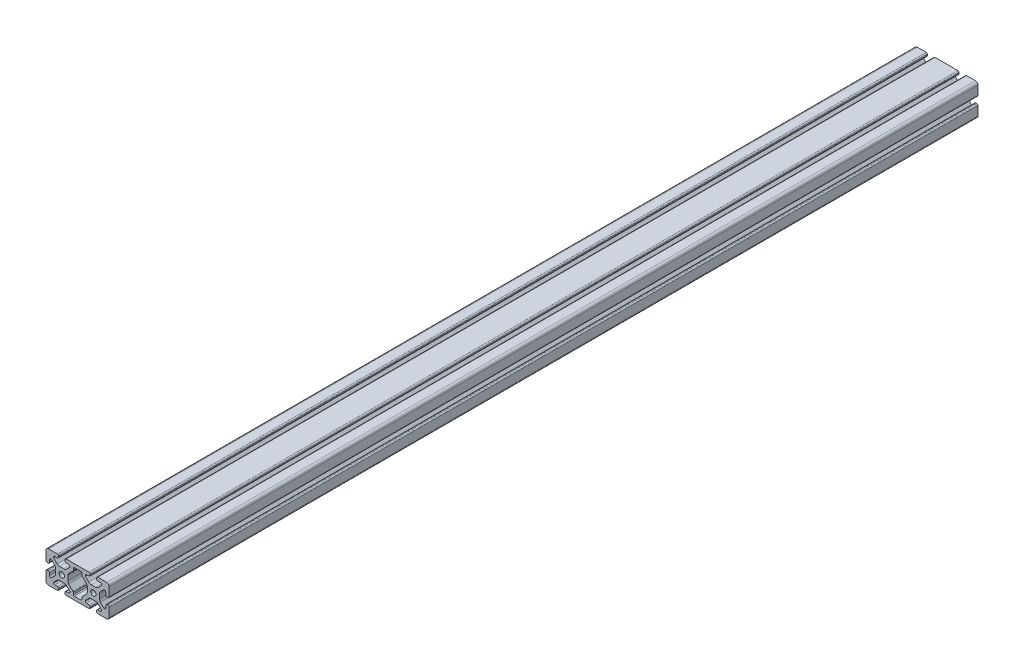
from build123d import *

# Parameters (mm, degrees)
SKETCH1_R           = 3.4
BOSS_EXTRUDE1_DEPTH = 1100


with BuildPart() as part:
    # Sketch1 → Boss-Extrude1 (new body)
    with BuildSketch(Plane.XY):
        with BuildLine():
            Line((-14.371895096, 20), (14.371895096, 20))
            ThreePointArc((14.371895096, 20), (15.50899084, 19.51254943), (15.94, 18.352883145))
            Line((15.94, 18.352883145), (15.94, 17.172883145))
            ThreePointArc((15.94, 17.172883145), (15.453758432, 16.112250378), (14.37, 15.68))
            Line((14.37, 15.68), (11.285, 15.68))
            ThreePointArc((11.285, 15.68), (10.174842354, 15.220157646), (9.715, 14.11))
            Line((9.715, 14.11), (9.715, 13.654503602))
            ThreePointArc((9.715, 13.654503602), (9.772851555, 13.363664194), (9.937598846, 13.117102448))
            Line((9.937598846, 13.117102448), (14.091872782, 8.962828513))
            ThreePointArc((14.091872782, 8.962828513), (15.647416634, 8.002049766), (17.450629992, 7.7))
            Line((17.450629992, 7.7), (22.549370008, 7.7))
            ThreePointArc((22.549370008, 7.7), (24.352583366, 8.002049766), (25.908127218, 8.962828513))
            Line((25.908127218, 8.962828513), (30.062401154, 13.117102448))
            ThreePointArc((30.062401154, 13.117102448), (30.227148445, 13.363664194), (30.285, 13.654503602))
            Line((30.285, 13.654503602), (30.285, 14.11))
            ThreePointArc((30.285, 14.11), (29.825157646, 15.220157646), (28.715, 15.68))
            Line((28.715, 15.68), (25.63, 15.68))
            ThreePointArc((25.63, 15.68), (24.519842354, 16.139842354), (24.06, 17.25))
            Line((24.06, 17.25), (24.06, 18.431164164))
            ThreePointArc((24.06, 18.431164164), (24.498672143, 19.519739968), (25.569550674, 20))
            Line((25.569550674, 20), (33, 20))
            Line((33, 20), (36.83, 20))
            ThreePointArc((36.83, 20), (39.067780363, 19.075288119), (40, 16.840624931))
            Line((40, 16.840624931), (40, 13.010624931))
            Line((40, 13.010624931), (40, 5.582508737))
            ThreePointArc((40, 5.582508737), (39.486387554, 4.464397964), (38.324306777, 4.06))
            Line((38.324306777, 4.06), (37.144306789, 4.06))
            ThreePointArc((37.144306789, 4.06), (36.103082753, 4.554299861), (35.68, 5.626438298))
            Line((35.68, 5.626438298), (35.68, 8.711438298))
            ThreePointArc((35.68, 8.711438298), (35.220157646, 9.821595945), (34.11, 10.281438298))
            Line((34.11, 10.281438298), (33.650941901, 10.281438298))
            ThreePointArc((33.650941901, 10.281438298), (33.360102492, 10.223586743), (33.113540747, 10.058839452))
            Line((33.113540747, 10.058839452), (29.01112516, 5.956423865))
            ThreePointArc((29.01112516, 5.956423865), (28.027864944, 4.392105869), (27.715866667, 2.570966522))
            Line((27.715866667, 2.570966522), (27.715866667, -2.502014759))
            ThreePointArc((27.715866667, -2.502014759), (27.988460835, -4.298258683), (28.915473265, -5.86077197))
            Line((28.915473265, -5.86077197), (33.171894658, -10.117193363))
            ThreePointArc((33.171894658, -10.117193363), (33.418456403, -10.281940654), (33.709295811, -10.339792209))
            Line((33.709295811, -10.339792209), (34.110956402, -10.339792209))
            ThreePointArc((34.110956402, -10.339792209), (35.240319888, -9.860405851), (35.68, -8.714999999))
            Line((35.68, -8.714999999), (35.68, -5.629999999))
            ThreePointArc((35.68, -5.629999999), (36.139842353, -4.519842353), (37.249999999, -4.06))
            Line((37.249999999, -4.06), (38.431164149, -4.06))
            ThreePointArc((38.431164149, -4.06), (39.519739962, -4.498672137), (40, -5.569550674))
            Line((40, -5.569550674), (40, -13))
            Line((40, -13), (40, -16.83))
            ThreePointArc((40, -16.83), (39.153330856, -18.99480488), (37.057427332, -20))
            Line((37.057427332, -20), (33.227427332, -20))
            Line((33.227427332, -20), (25.796978006, -20))
            ThreePointArc((25.796978006, -20), (24.580537154, -19.606606664), (24.06, -18.438904761))
            Line((24.06, -18.438904761), (24.06, -17.25))
            ThreePointArc((24.06, -17.25), (24.519842354, -16.139842354), (25.63, -15.68))
            Line((25.63, -15.68), (28.715, -15.68))
            ThreePointArc((28.715, -15.68), (29.825157646, -15.220157646), (30.285, -14.11))
            Line((30.285, -14.11), (30.285, -13.654503602))
            ThreePointArc((30.285, -13.654503602), (30.227148445, -13.363664194), (30.062401154, -13.117102448))
            Line((30.062401154, -13.117102448), (26.309520343, -9.364221638))
            ThreePointArc((26.309520343, -9.364221638), (24.979669869, -8.257223741), (23.341546451, -7.7))
            Line((23.341546451, -7.7), (16.658453549, -7.7))
            ThreePointArc((16.658453549, -7.7), (15.020330131, -8.257223741), (13.690479657, -9.364221638))
            Line((13.690479657, -9.364221638), (9.937598846, -13.117102448))
            ThreePointArc((9.937598846, -13.117102448), (9.772851555, -13.363664194), (9.715, -13.654503602))
            Line((9.715, -13.654503602), (9.715, -14.11))
            ThreePointArc((9.715, -14.11), (10.174842354, -15.220157646), (11.285, -15.68))
            Line((11.285, -15.68), (14.37, -15.68))
            ThreePointArc((14.37, -15.68), (15.480157646, -16.139842354), (15.94, -17.25))
            Line((15.94, -17.25), (15.94, -18.43))
            ThreePointArc((15.94, -18.43), (15.480157646, -19.540157646), (14.37, -20))
            Line((14.37, -20), (5.99100603, -20))
            Line((5.99100603, -20), (-1.780052417, -20))
            Line((-1.780052417, -20), (-5.99100603, -20))
            Line((-5.99100603, -20), (-14.37, -20))
            ThreePointArc((-14.37, -20), (-15.480157646, -19.540157646), (-15.94, -18.43))
            Line((-15.94, -18.43), (-15.94, -17.25))
            ThreePointArc((-15.94, -17.25), (-15.480157646, -16.139842354), (-14.37, -15.68))
            Line((-14.37, -15.68), (-11.285, -15.68))
            ThreePointArc((-11.285, -15.68), (-10.174842354, -15.220157646), (-9.715, -14.11))
            Line((-9.715, -14.11), (-9.715, -13.654503602))
            ThreePointArc((-9.715, -13.654503602), (-9.772851555, -13.363664194), (-9.937598846, -13.117102448))
            Line((-9.937598846, -13.117102448), (-13.690479657, -9.364221638))
            ThreePointArc((-13.690479657, -9.364221638), (-15.020330131, -8.257223741), (-16.658453549, -7.7))
            Line((-16.658453549, -7.7), (-23.341546451, -7.7))
            ThreePointArc((-23.341546451, -7.7), (-24.979669869, -8.257223741), (-26.309520343, -9.364221638))
            Line((-26.309520343, -9.364221638), (-30.062401154, -13.117102448))
            ThreePointArc((-30.062401154, -13.117102448), (-30.227148445, -13.363664194), (-30.285, -13.654503602))
            Line((-30.285, -13.654503602), (-30.285, -14.11))
            ThreePointArc((-30.285, -14.11), (-29.825157646, -15.220157646), (-28.715, -15.68))
            Line((-28.715, -15.68), (-25.63, -15.68))
            ThreePointArc((-25.63, -15.68), (-24.519842354, -16.139842354), (-24.06, -17.25))
            Line((-24.06, -17.25), (-24.06, -18.438904761))
            ThreePointArc((-24.06, -18.438904761), (-24.580537154, -19.606606664), (-25.796978006, -20))
            Line((-25.796978006, -20), (-33.227427332, -20))
            Line((-33.227427332, -20), (-37.057427332, -20))
            ThreePointArc((-37.057427332, -20), (-39.153330856, -18.99480488), (-40, -16.83))
            Line((-40, -16.83), (-40, -13))
            Line((-40, -13), (-40, -5.569550674))
            ThreePointArc((-40, -5.569550674), (-39.519320595, -4.498268351), (-38.43, -4.06))
            Line((-38.43, -4.06), (-37.249999999, -4.06))
            ThreePointArc((-37.249999999, -4.06), (-36.139842353, -4.519842353), (-35.68, -5.629999999))
            Line((-35.68, -5.629999999), (-35.68, -8.714999999))
            ThreePointArc((-35.68, -8.714999999), (-35.240319888, -9.860405851), (-34.110956402, -10.339792209))
            Line((-34.110956402, -10.339792209), (-33.709295811, -10.339792209))
            ThreePointArc((-33.709295811, -10.339792209), (-33.418456403, -10.281940654), (-33.171894658, -10.117193363))
            Line((-33.171894658, -10.117193363), (-28.915473265, -5.86077197))
            ThreePointArc((-28.915473265, -5.86077197), (-27.988460835, -4.298258683), (-27.715866667, -2.502014759))
            Line((-27.715866667, -2.502014759), (-27.715866667, 2.570966522))
            ThreePointArc((-27.715866667, 2.570966522), (-28.027864944, 4.392105869), (-29.01112516, 5.956423865))
            Line((-29.01112516, 5.956423865), (-33.113540747, 10.058839452))
            ThreePointArc((-33.113540747, 10.058839452), (-33.360102492, 10.223586743), (-33.650941901, 10.281438298))
            Line((-33.650941901, 10.281438298), (-34.11, 10.281438298))
            ThreePointArc((-34.11, 10.281438298), (-35.220157646, 9.821595945), (-35.68, 8.711438298))
            Line((-35.68, 8.711438298), (-35.68, 5.626438298))
            ThreePointArc((-35.68, 5.626438298), (-36.103082753, 4.554299861), (-37.144306789, 4.06))
            Line((-37.144306789, 4.06), (-38.324306777, 4.06))
            ThreePointArc((-38.324306777, 4.06), (-39.486387554, 4.464397964), (-40, 5.582508737))
            Line((-40, 5.582508737), (-40, 13.010624931))
            Line((-40, 13.010624931), (-40, 16.840624931))
            ThreePointArc((-40, 16.840624931), (-39.067780363, 19.075288119), (-36.83, 20))
            Line((-36.83, 20), (-33, 20))
            Line((-33, 20), (-25.569550674, 20))
            ThreePointArc((-25.569550674, 20), (-24.498672143, 19.519739968), (-24.06, 18.431164164))
            Line((-24.06, 18.431164164), (-24.06, 17.25))
            ThreePointArc((-24.06, 17.25), (-24.519842354, 16.139842354), (-25.63, 15.68))
            Line((-25.63, 15.68), (-28.715, 15.68))
            ThreePointArc((-28.715, 15.68), (-29.825157646, 15.220157646), (-30.285, 14.11))
            Line((-30.285, 14.11), (-30.285, 13.654503602))
            ThreePointArc((-30.285, 13.654503602), (-30.227148445, 13.363664194), (-30.062401154, 13.117102448))
            Line((-30.062401154, 13.117102448), (-25.908127218, 8.962828513))
            ThreePointArc((-25.908127218, 8.962828513), (-24.352583366, 8.002049766), (-22.549370008, 7.7))
            Line((-22.549370008, 7.7), (-17.450629992, 7.7))
            ThreePointArc((-17.450629992, 7.7), (-15.647416634, 8.002049766), (-14.091872782, 8.962828513))
            Line((-14.091872782, 8.962828513), (-9.937598846, 13.117102448))
            ThreePointArc((-9.937598846, 13.117102448), (-9.772851555, 13.363664194), (-9.715, 13.654503602))
            Line((-9.715, 13.654503602), (-9.715, 14.11))
            ThreePointArc((-9.715, 14.11), (-10.174842354, 15.220157646), (-11.285, 15.68))
            Line((-11.285, 15.68), (-14.37, 15.68))
            ThreePointArc((-14.37, 15.68), (-15.453758432, 16.112250378), (-15.94, 17.172883145))
            Line((-15.94, 17.172883145), (-15.94, 18.352883145))
            ThreePointArc((-15.94, 18.352883145), (-15.50899084, 19.51254943), (-14.371895096, 20))
        make_face()
        with Locations((-20, 0)):
            Circle(SKETCH1_R, mode=Mode.SUBTRACT)
        with Locations((20, 0)):
            Circle(SKETCH1_R, mode=Mode.SUBTRACT)
        with BuildLine():
            Line((4.071751167, 15.68), (-4.071751167, 15.68))
            ThreePointArc((-4.071751167, 15.68), (-4.969776779, 15.308025612), (-5.341751167, 14.41))
            Line((-5.341751167, 14.41), (-5.341751167, 12.129598762))
            ThreePointArc((-5.341751167, 12.129598762), (-5.438424161, 11.643590803), (-5.713725555, 11.23157315))
            Line((-5.713725555, 11.23157315), (-10.598777023, 6.346521682))
            ThreePointArc((-10.598777023, 6.346521682), (-11.737774423, 4.964558417), (-12.284133333, 3.259087959))
            Line((-12.284133333, 3.259087959), (-12.284133333, -2.724972544))
            ThreePointArc((-12.284133333, -2.724972544), (-12.005210609, -4.328708179), (-11.201199443, -5.744099262))
            Line((-11.201199443, -5.744099262), (-5.713725555, -11.23157315))
            ThreePointArc((-5.713725555, -11.23157315), (-5.438424161, -11.643590803), (-5.341751167, -12.129598762))
            Line((-5.341751167, -12.129598762), (-5.341751167, -14.41))
            ThreePointArc((-5.341751167, -14.41), (-4.969776779, -15.308025612), (-4.071751167, -15.68))
            Line((-4.071751167, -15.68), (4.071751167, -15.68))
            ThreePointArc((4.071751167, -15.68), (4.969776779, -15.308025612), (5.341751167, -14.41))
            Line((5.341751167, -14.41), (5.341751167, -12.129598762))
            ThreePointArc((5.341751167, -12.129598762), (5.438424161, -11.643590803), (5.713725555, -11.23157315))
            Line((5.713725555, -11.23157315), (11.201199443, -5.744099262))
            ThreePointArc((11.201199443, -5.744099262), (12.005210609, -4.328708179), (12.284133333, -2.724972544))
            Line((12.284133333, -2.724972544), (12.284133333, 3.259087959))
            ThreePointArc((12.284133333, 3.259087959), (11.737774423, 4.964558417), (10.598777023, 6.346521682))
            Line((10.598777023, 6.346521682), (5.713725555, 11.23157315))
            ThreePointArc((5.713725555, 11.23157315), (5.438424161, 11.643590803), (5.341751167, 12.129598762))
            Line((5.341751167, 12.129598762), (5.341751167, 14.41))
            ThreePointArc((5.341751167, 14.41), (4.969776779, 15.308025612), (4.071751167, 15.68))
        make_face(mode=Mode.SUBTRACT)
    extrude(amount=BOSS_EXTRUDE1_DEPTH)


solid = part.part
